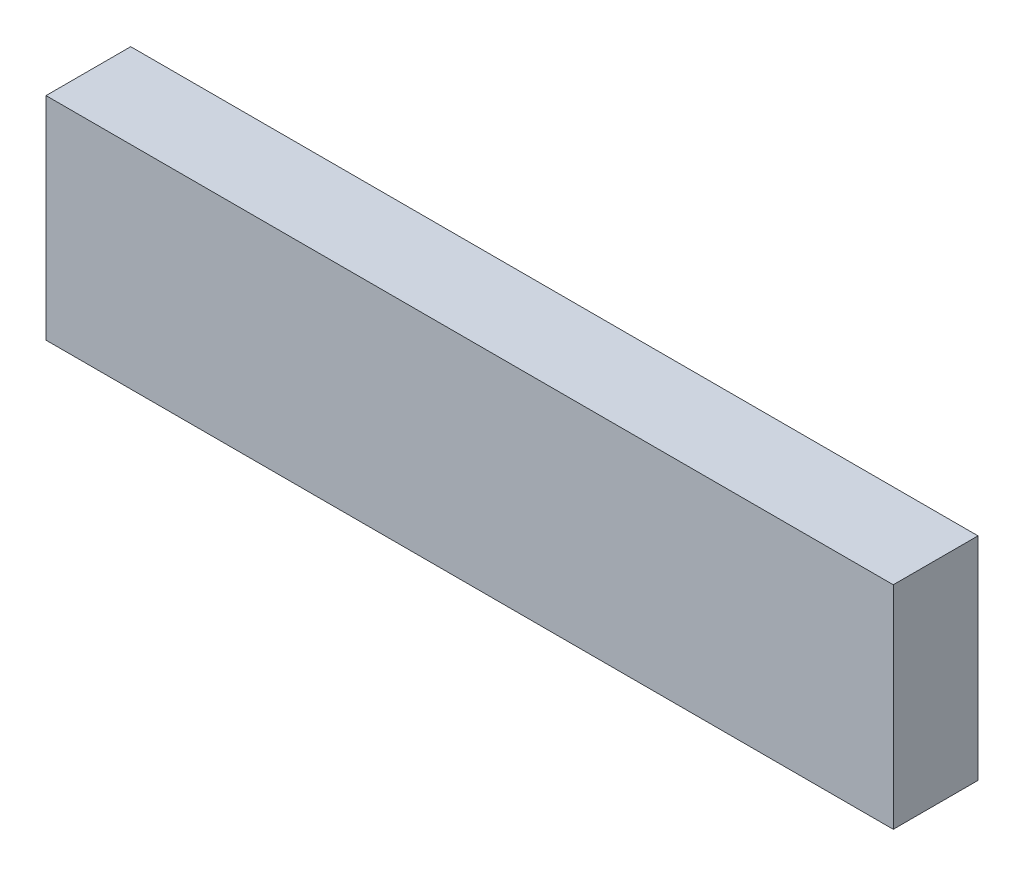
from build123d import *

# Parameters (mm, degrees)
SKETCH1_W           = 1000
SKETCH1_H           = 100
BOSS_EXTRUDE1_DEPTH = 250


with BuildPart() as part:
    # Sketch1 → Boss-Extrude1 (new body)
    with BuildSketch(Plane(origin=(0, 0, 0), x_dir=(1, 0, 0), z_dir=(0, 1, 0))):
        Rectangle(SKETCH1_W, SKETCH1_H)
    extrude(amount=-BOSS_EXTRUDE1_DEPTH)


solid = part.part
